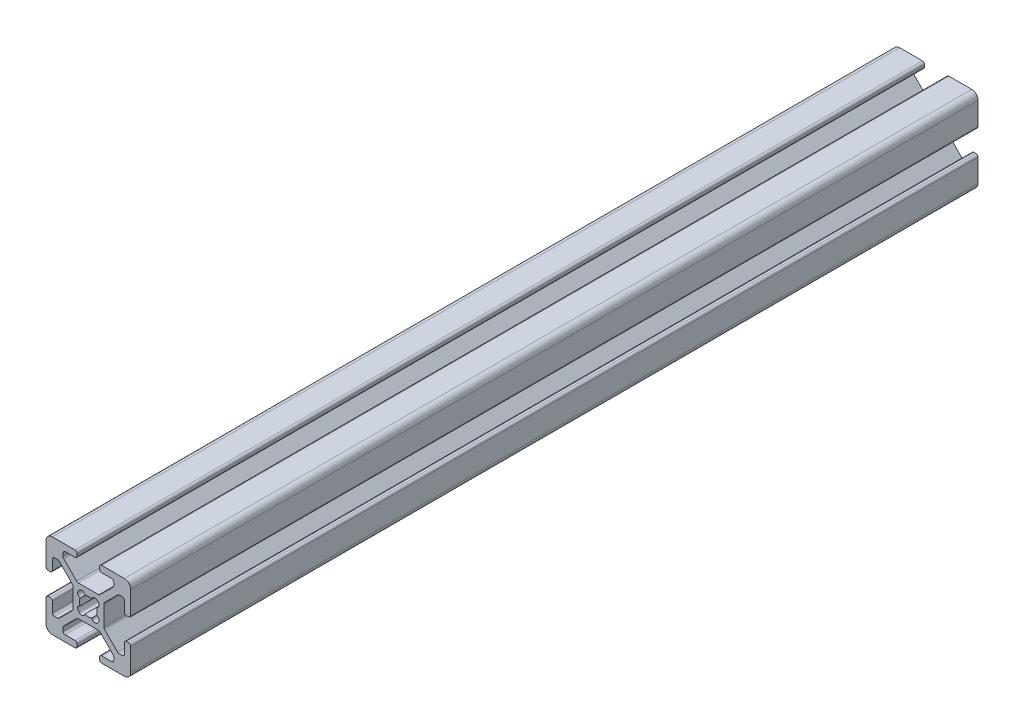
from build123d import *

# Parameters (mm, degrees)
EXTRUDE1_DEPTH = 200


with BuildPart() as part:
    # Sketch1 → Extrude1 (new body)
    with BuildSketch(Plane.XY):
        with BuildLine():
            Line((-5.032287798, -0.341059771), (-5.516287798, -0.341059771))
            ThreePointArc((-5.516287798, -0.341059771), (-5.875498042, -0.192270016), (-6.024287798, 0.166940229))
            Line((-6.024287798, 0.166940229), (-6.024287798, 2.515940229))
            ThreePointArc((-6.024287798, 2.515940229), (-6.173077553, 2.875150474), (-6.532287798, 3.023940229))
            Line((-6.532287798, 3.023940229), (-7.258207136, 3.023940229))
            ThreePointArc((-7.258207136, 3.023940229), (-7.45261032, 2.985271032), (-7.617417381, 2.875150474))
            Line((-7.617417381, 2.875150474), (-10.720498042, -0.227930187))
            ThreePointArc((-10.720498042, -0.227930187), (-10.8306186, -0.392737249), (-10.869287798, -0.587140432))
            Line((-10.869287798, -0.587140432), (-10.869287798, -5.354979109))
            ThreePointArc((-10.869287798, -5.354979109), (-10.8306186, -5.549382293), (-10.720498042, -5.714189354))
            Line((-10.720498042, -5.714189354), (-7.617417381, -8.817270016))
            ThreePointArc((-7.617417381, -8.817270016), (-7.45261032, -8.927390573), (-7.258207136, -8.966059771))
            Line((-7.258207136, -8.966059771), (-6.532287798, -8.966059771))
            ThreePointArc((-6.532287798, -8.966059771), (-6.173077553, -8.817270016), (-6.024287798, -8.458059771))
            Line((-6.024287798, -8.458059771), (-6.024287798, -6.109059771))
            ThreePointArc((-6.024287798, -6.109059771), (-5.875498042, -5.749849526), (-5.516287798, -5.601059771))
            Line((-5.516287798, -5.601059771), (-5.032287798, -5.601059771))
            ThreePointArc((-5.032287798, -5.601059771), (-4.673077553, -5.749849526), (-4.524287798, -6.109059771))
            Line((-4.524287798, -6.109059771), (-4.524287798, -11.471059771))
            ThreePointArc((-4.524287798, -11.471059771), (-4.963627626, -12.531719943), (-6.024287798, -12.971059771))
            Line((-6.024287798, -12.971059771), (-11.386287798, -12.971059771))
            ThreePointArc((-11.386287798, -12.971059771), (-11.745498042, -12.822270016), (-11.894287798, -12.463059771))
            Line((-11.894287798, -12.463059771), (-11.894287798, -11.979059771))
            ThreePointArc((-11.894287798, -11.979059771), (-11.745498042, -11.619849526), (-11.386287798, -11.471059771))
            Line((-11.386287798, -11.471059771), (-9.037287798, -11.471059771))
            ThreePointArc((-9.037287798, -11.471059771), (-8.678077553, -11.322270016), (-8.529287798, -10.963059771))
            Line((-8.529287798, -10.963059771), (-8.529287798, -10.237140432))
            ThreePointArc((-8.529287798, -10.237140432), (-8.567956995, -10.042737249), (-8.678077553, -9.877930187))
            Line((-8.678077553, -9.877930187), (-11.781158214, -6.774849526))
            ThreePointArc((-11.781158214, -6.774849526), (-11.945965275, -6.664728968), (-12.140368459, -6.626059771))
            Line((-12.140368459, -6.626059771), (-16.908207136, -6.626059771))
            ThreePointArc((-16.908207136, -6.626059771), (-17.10261032, -6.664728968), (-17.267417381, -6.774849526))
            Line((-17.267417381, -6.774849526), (-20.370498042, -9.877930187))
            ThreePointArc((-20.370498042, -9.877930187), (-20.4806186, -10.042737249), (-20.519287798, -10.237140432))
            Line((-20.519287798, -10.237140432), (-20.519287798, -10.963059771))
            ThreePointArc((-20.519287798, -10.963059771), (-20.370498042, -11.322270016), (-20.011287798, -11.471059771))
            Line((-20.011287798, -11.471059771), (-17.662287798, -11.471059771))
            ThreePointArc((-17.662287798, -11.471059771), (-17.303077553, -11.619849526), (-17.154287798, -11.979059771))
            Line((-17.154287798, -11.979059771), (-17.154287798, -12.463059771))
            ThreePointArc((-17.154287798, -12.463059771), (-17.303077553, -12.822270016), (-17.662287798, -12.971059771))
            Line((-17.662287798, -12.971059771), (-23.024287798, -12.971059771))
            ThreePointArc((-23.024287798, -12.971059771), (-24.084947969, -12.531719943), (-24.524287798, -11.471059771))
            Line((-24.524287798, -11.471059771), (-24.524287798, -6.109059771))
            ThreePointArc((-24.524287798, -6.109059771), (-24.375498042, -5.749849526), (-24.016287798, -5.601059771))
            Line((-24.016287798, -5.601059771), (-23.532287798, -5.601059771))
            ThreePointArc((-23.532287798, -5.601059771), (-23.173077553, -5.749849526), (-23.024287798, -6.109059771))
            Line((-23.024287798, -6.109059771), (-23.024287798, -8.458059771))
            ThreePointArc((-23.024287798, -8.458059771), (-22.875498042, -8.817270016), (-22.516287798, -8.966059771))
            Line((-22.516287798, -8.966059771), (-21.790368459, -8.966059771))
            ThreePointArc((-21.790368459, -8.966059771), (-21.595965275, -8.927390573), (-21.431158214, -8.817270016))
            Line((-21.431158214, -8.817270016), (-18.328077553, -5.714189354))
            ThreePointArc((-18.328077553, -5.714189354), (-18.217956995, -5.549382293), (-18.179287798, -5.354979109))
            Line((-18.179287798, -5.354979109), (-18.179287798, -0.587140432))
            ThreePointArc((-18.179287798, -0.587140432), (-18.217956995, -0.392737249), (-18.328077553, -0.227930187))
            Line((-18.328077553, -0.227930187), (-21.431158214, 2.875150474))
            ThreePointArc((-21.431158214, 2.875150474), (-21.595965275, 2.985271032), (-21.790368459, 3.023940229))
            Line((-21.790368459, 3.023940229), (-22.516287798, 3.023940229))
            ThreePointArc((-22.516287798, 3.023940229), (-22.875498042, 2.875150474), (-23.024287798, 2.515940229))
            Line((-23.024287798, 2.515940229), (-23.024287798, 0.166940229))
            ThreePointArc((-23.024287798, 0.166940229), (-23.173077553, -0.192270016), (-23.532287798, -0.341059771))
            Line((-23.532287798, -0.341059771), (-24.016287798, -0.341059771))
            ThreePointArc((-24.016287798, -0.341059771), (-24.375498042, -0.192270016), (-24.524287798, 0.166940229))
            Line((-24.524287798, 0.166940229), (-24.524287798, 5.528940229))
            ThreePointArc((-24.524287798, 5.528940229), (-24.084947969, 6.589600401), (-23.024287798, 7.028940229))
            Line((-23.024287798, 7.028940229), (-17.662287798, 7.028940229))
            ThreePointArc((-17.662287798, 7.028940229), (-17.303077553, 6.880150474), (-17.154287798, 6.520940229))
            Line((-17.154287798, 6.520940229), (-17.154287798, 6.036940229))
            ThreePointArc((-17.154287798, 6.036940229), (-17.303077553, 5.677729984), (-17.662287798, 5.528940229))
            Line((-17.662287798, 5.528940229), (-20.011287798, 5.528940229))
            ThreePointArc((-20.011287798, 5.528940229), (-20.370498042, 5.380150474), (-20.519287798, 5.020940229))
            Line((-20.519287798, 5.020940229), (-20.519287798, 4.295020891))
            ThreePointArc((-20.519287798, 4.295020891), (-20.4806186, 4.100617707), (-20.370498042, 3.935810646))
            Line((-20.370498042, 3.935810646), (-17.267417381, 0.832729984))
            ThreePointArc((-17.267417381, 0.832729984), (-17.10261032, 0.722609427), (-16.908207136, 0.683940229))
            Line((-16.908207136, 0.683940229), (-12.140368459, 0.683940229))
            ThreePointArc((-12.140368459, 0.683940229), (-11.945965275, 0.722609427), (-11.781158214, 0.832729984))
            Line((-11.781158214, 0.832729984), (-8.678077553, 3.935810646))
            ThreePointArc((-8.678077553, 3.935810646), (-8.567956995, 4.100617707), (-8.529287798, 4.295020891))
            Line((-8.529287798, 4.295020891), (-8.529287798, 5.020940229))
            ThreePointArc((-8.529287798, 5.020940229), (-8.678077553, 5.380150474), (-9.037287798, 5.528940229))
            Line((-9.037287798, 5.528940229), (-11.386287798, 5.528940229))
            ThreePointArc((-11.386287798, 5.528940229), (-11.745498042, 5.677729984), (-11.894287798, 6.036940229))
            Line((-11.894287798, 6.036940229), (-11.894287798, 6.520940229))
            ThreePointArc((-11.894287798, 6.520940229), (-11.745498042, 6.880150474), (-11.386287798, 7.028940229))
            Line((-11.386287798, 7.028940229), (-6.024287798, 7.028940229))
            ThreePointArc((-6.024287798, 7.028940229), (-4.963627626, 6.589600401), (-4.524287798, 5.528940229))
            Line((-4.524287798, 5.528940229), (-4.524287798, 0.166940229))
            ThreePointArc((-4.524287798, 0.166940229), (-4.673077553, -0.192270016), (-5.032287798, -0.341059771))
        make_face()
        with BuildLine():
            Line((-12.399386954, -5.275565737), (-12.219781831, -5.095960615))
            ThreePointArc((-12.219781831, -5.095960615), (-12.018349781, -4.327527582), (-12.589154291, -3.775036489))
            ThreePointArc((-12.589154291, -3.775036489), (-12.428787798, -2.971059771), (-12.589154291, -2.167083053))
            ThreePointArc((-12.589154291, -2.167083053), (-12.018349781, -1.61459196), (-12.219781831, -0.846158927))
            Line((-12.219781831, -0.846158927), (-12.399386954, -0.666553805))
            ThreePointArc((-12.399386954, -0.666553805), (-13.167819987, -0.465121754), (-13.72031108, -1.035926265))
            ThreePointArc((-13.72031108, -1.035926265), (-14.524287798, -0.875559771), (-15.328264516, -1.035926265))
            ThreePointArc((-15.328264516, -1.035926265), (-15.880755608, -0.465121754), (-16.649188641, -0.666553805))
            Line((-16.649188641, -0.666553805), (-16.828793764, -0.846158927))
            ThreePointArc((-16.828793764, -0.846158927), (-17.030225814, -1.61459196), (-16.459421304, -2.167083053))
            ThreePointArc((-16.459421304, -2.167083053), (-16.619787798, -2.971059771), (-16.459421304, -3.775036489))
            ThreePointArc((-16.459421304, -3.775036489), (-17.030225814, -4.327527582), (-16.828793764, -5.095960615))
            Line((-16.828793764, -5.095960615), (-16.649188641, -5.275565737))
            ThreePointArc((-16.649188641, -5.275565737), (-15.880755608, -5.476997788), (-15.328264516, -4.906193277))
            ThreePointArc((-15.328264516, -4.906193277), (-14.524287798, -5.066559771), (-13.72031108, -4.906193277))
            ThreePointArc((-13.72031108, -4.906193277), (-13.167819987, -5.476997788), (-12.399386954, -5.275565737))
        make_face(mode=Mode.SUBTRACT)
    extrude(amount=EXTRUDE1_DEPTH)


solid = part.part
